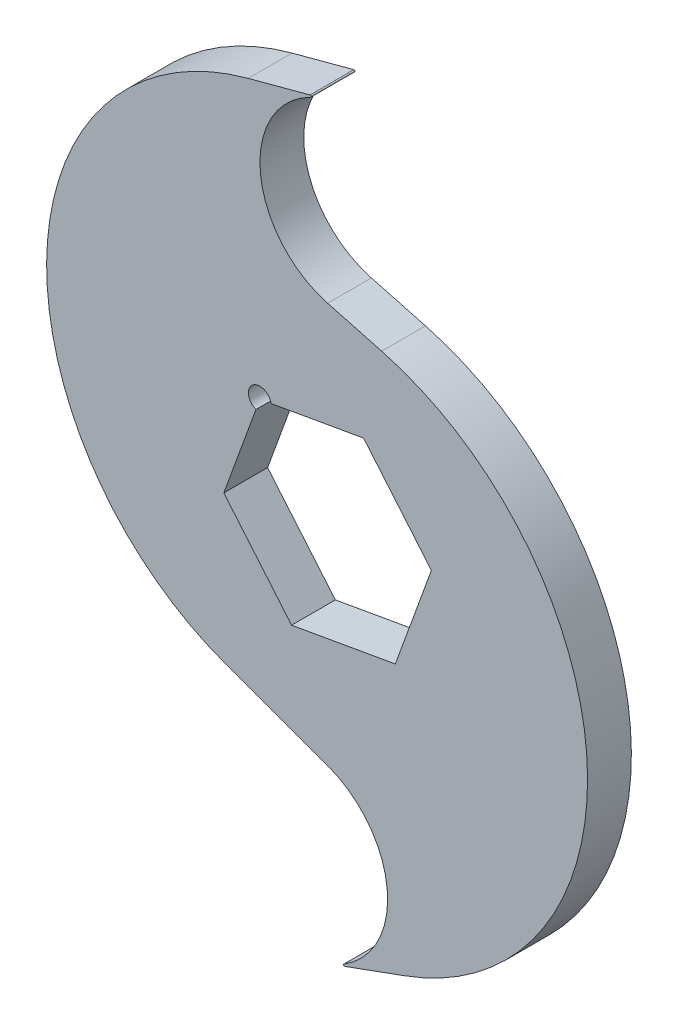
from build123d import *

# Parameters (mm, degrees)
BOSS_EXTRUDE1_DEPTH = 3.048
FILLET1_R           = 0.127


with BuildPart() as part:
    # Sketch1 → Boss-Extrude1 (new body, symmetric)
    with BuildSketch(Plane.XY):
        with BuildLine():
            ThreePointArc((0, 27.535484012), (-9.412998127, 39.802742006), (0, 52.07))
            Line((0, 52.07), (-11.040532194, 49.111698314))
            ThreePointArc((-11.040532194, 49.111698314), (-39.066320922, 14.192289272), (-14.190605813, -23.03684931))
            Line((-14.190605813, -23.03684931), (0, -28.201807432))
            ThreePointArc((0, -28.201807432), (8.35634418, -40.135903716), (0, -52.07))
            Line((0, -52.07), (10.740686656, -48.160709762))
            ThreePointArc((10.740686656, -48.160709762), (36.144496882, -10.141220984), (7.52373904, 25.519504212))
            Line((7.52373904, 25.519504212), (0, 27.535484012))
        make_face()
        with BuildLine():
            Line((-14.441907141, -2.546497882), (-9.969242404, 9.742047487))
            ThreePointArc((-9.969242404, 9.742047487), (-10.446710757, 12.449905076), (-7.862903119, 11.509476004))
            Line((-7.862903119, 11.509476004), (5.015621714, 13.780307404))
            Line((5.015621714, 13.780307404), (14.441907141, 2.546497882))
            Line((14.441907141, 2.546497882), (9.426285427, -11.233809522))
            Line((9.426285427, -11.233809522), (-5.015621714, -13.780307404))
            Line((-5.015621714, -13.780307404), (-14.441907141, -2.546497882))
        make_face(mode=Mode.SUBTRACT)
    extrude(amount=BOSS_EXTRUDE1_DEPTH, both=True)

    # Fillet1
    fillet1_edges = [part.edges().sort_by_distance(p)[0] for p in [
        (0, 52.07, 0),
        (0, -52.07, 0),
    ]]
    fillet(fillet1_edges, radius=FILLET1_R)


solid = part.part
